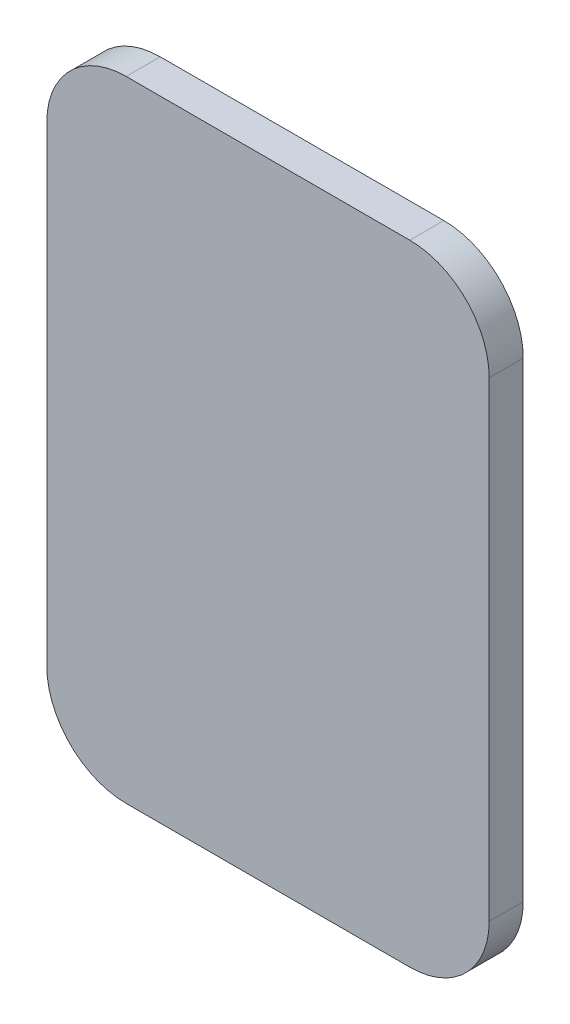
from build123d import *

# Parameters (mm, degrees)
BOSS_EXTRUDE1_DEPTH = 6


with BuildPart() as part:
    # Sketch1 → Boss-Extrude1 (new body)
    with BuildSketch(Plane.XY):
        with BuildLine():
            Line((-25, 55.5), (25, 55.5))
            ThreePointArc((25, 55.5), (34.899494937, 51.399494937), (39, 41.5))
            Line((39, 41.5), (39, -41.5))
            ThreePointArc((39, -41.5), (34.899494937, -51.399494937), (25, -55.5))
            Line((25, -55.5), (-25, -55.5))
            ThreePointArc((-25, -55.5), (-34.899494937, -51.399494937), (-39, -41.5))
            Line((-39, -41.5), (-39, 41.5))
            ThreePointArc((-39, 41.5), (-34.899494937, 51.399494937), (-25, 55.5))
        make_face()
    extrude(amount=BOSS_EXTRUDE1_DEPTH)


solid = part.part
